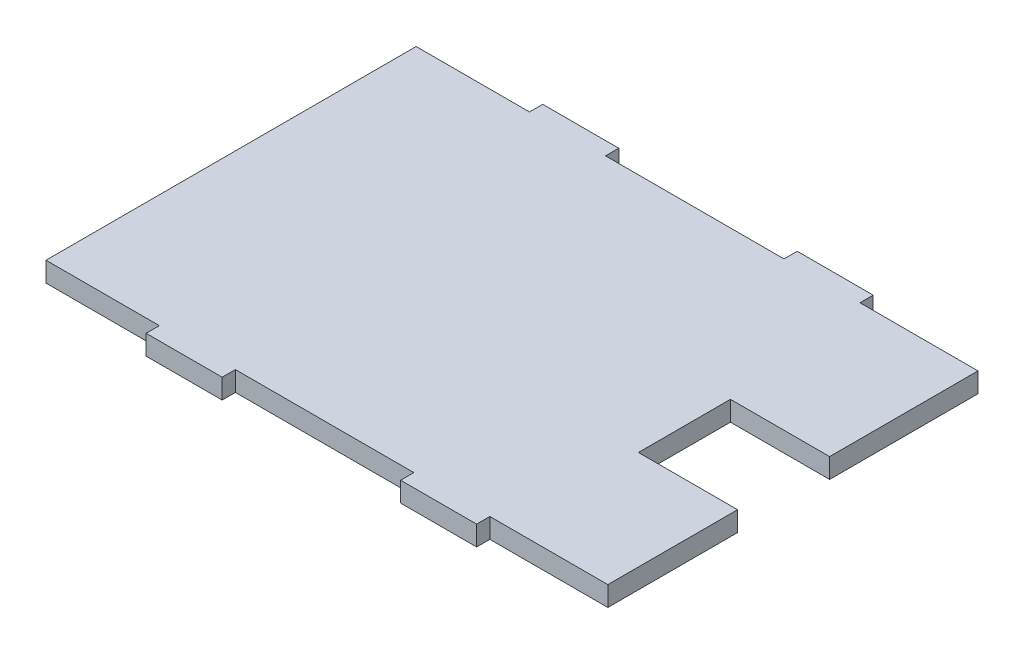
from build123d import *

# Parameters (mm, degrees)
BOSS_EXTRUDE1_DEPTH = 3.048


with BuildPart() as part:
    # Sketch1 → Boss-Extrude1 (new body)
    with BuildSketch(Plane(origin=(0, 0, 0), x_dir=(1, 0, 0), z_dir=(0, 1, 0))):
        Polygon((-25.7556, -28.448), (-25.7556, -30.48), (-14.0716, -30.48), (-14.0716, -28.448), (13.3604, -28.448), (13.3604, -30.48), (25.0444, -30.48), (25.0444, -28.448), (43.18, -28.448), (43.18, -8.509), (27.94, -8.509), (27.94, 5.6388), (43.18, 5.6388), (43.18, 28.448), (25.0444, 28.448), (25.0444, 30.48), (13.3604, 30.48), (13.3604, 28.448), (-14.0716, 28.448), (-14.0716, 30.48), (-25.7556, 30.48), (-25.7556, 28.448), (-43.18, 28.448), (-43.18, -28.448), align=None)
    extrude(amount=BOSS_EXTRUDE1_DEPTH)


solid = part.part
